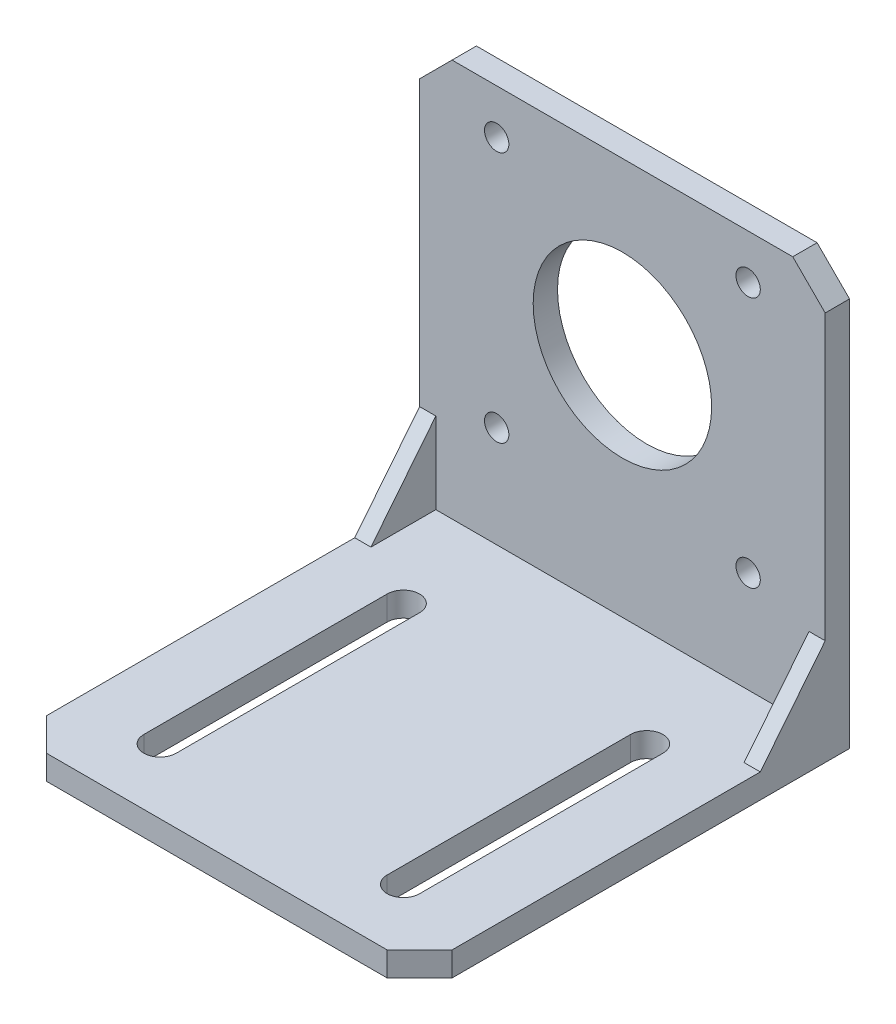
from build123d import *

# Parameters (mm, degrees)
SKETCH1_W           = 50
SKETCH1_H           = 52
SKETCH1_R           = 11
SKETCH1_R_2         = 1.5
BOSS_EXTRUDE1_DEPTH = 3
CHAMFER1_SIZE       = 4
SKETCH2_W           = 50
SKETCH2_H           = 3
BOSS_EXTRUDE2_DEPTH = 50
BOSS_EXTRUDE3_DEPTH = 2
BOSS_EXTRUDE4_DEPTH = 2
CHAMFER2_SIZE       = 4
CUT_EXTRUDE1_DEPTH  = 4


with BuildPart() as part:
    # Sketch1 → Boss-Extrude1 (new body)
    with BuildSketch(Plane.XY):
        Rectangle(SKETCH1_W, SKETCH1_H)
        with Locations((0, 5)):
            Circle(SKETCH1_R, mode=Mode.SUBTRACT)
        with Locations((-15.5, 20.5)):
            Circle(SKETCH1_R_2, mode=Mode.SUBTRACT)
        with Locations((15.5, 20.5)):
            Circle(SKETCH1_R_2, mode=Mode.SUBTRACT)
        with Locations((15.5, -10.5)):
            Circle(SKETCH1_R_2, mode=Mode.SUBTRACT)
        with Locations((-15.5, -10.5)):
            Circle(SKETCH1_R_2, mode=Mode.SUBTRACT)
    extrude(amount=BOSS_EXTRUDE1_DEPTH)

    # Chamfer1
    chamfer1_edges = [part.edges().sort_by_distance(p)[0] for p in [
        (-25, 26, 1.5),
        (25, 26, 1.5),
    ]]
    chamfer(chamfer1_edges, length=CHAMFER1_SIZE)

    # Sketch2 → Boss-Extrude2 (add)
    with BuildSketch(Plane.XY.offset(3)):
        with Locations((0, -24.5)):
            Rectangle(SKETCH2_W, SKETCH2_H)
    extrude(amount=BOSS_EXTRUDE2_DEPTH)

    # Sketch3 → Boss-Extrude3 (add)
    with BuildSketch(Plane(origin=(25, 0, 0), x_dir=(0, 0, -1), z_dir=(1, 0, 0))):
        Polygon((-3, -13), (-11, -23), (-3, -23), align=None)
    extrude(amount=-BOSS_EXTRUDE3_DEPTH)

    # Sketch4 → Boss-Extrude4 (add)
    with BuildSketch(Plane.ZY.offset(25)):
        Polygon((3, -13), (3, -23), (11, -23), align=None)
    extrude(amount=-BOSS_EXTRUDE4_DEPTH)

    # Chamfer2
    chamfer2_edges = [part.edges().sort_by_distance(p)[0] for p in [
        (-25, -24.5, 53),
        (25, -24.5, 53),
    ]]
    chamfer(chamfer2_edges, length=CHAMFER2_SIZE)

    # Sketch5 → Cut-Extrude1 (cut, through all)
    with BuildSketch(Plane(origin=(0, -23, 0), x_dir=(1, 0, 0), z_dir=(0, 1, 0))):
        with BuildLine():
            Line((-13, -15), (-13, -45))
            ThreePointArc((-13, -45), (-15, -47), (-17, -45))
            Line((-17, -45), (-17, -15))
            ThreePointArc((-17, -15), (-15, -13), (-13, -15))
        make_face()
        with BuildLine():
            Line((13, -15), (13, -45))
            ThreePointArc((13, -45), (15, -47), (17, -45))
            Line((17, -45), (17, -15))
            ThreePointArc((17, -15), (15, -13), (13, -15))
        make_face()
    extrude(amount=-CUT_EXTRUDE1_DEPTH, mode=Mode.SUBTRACT)


solid = part.part
